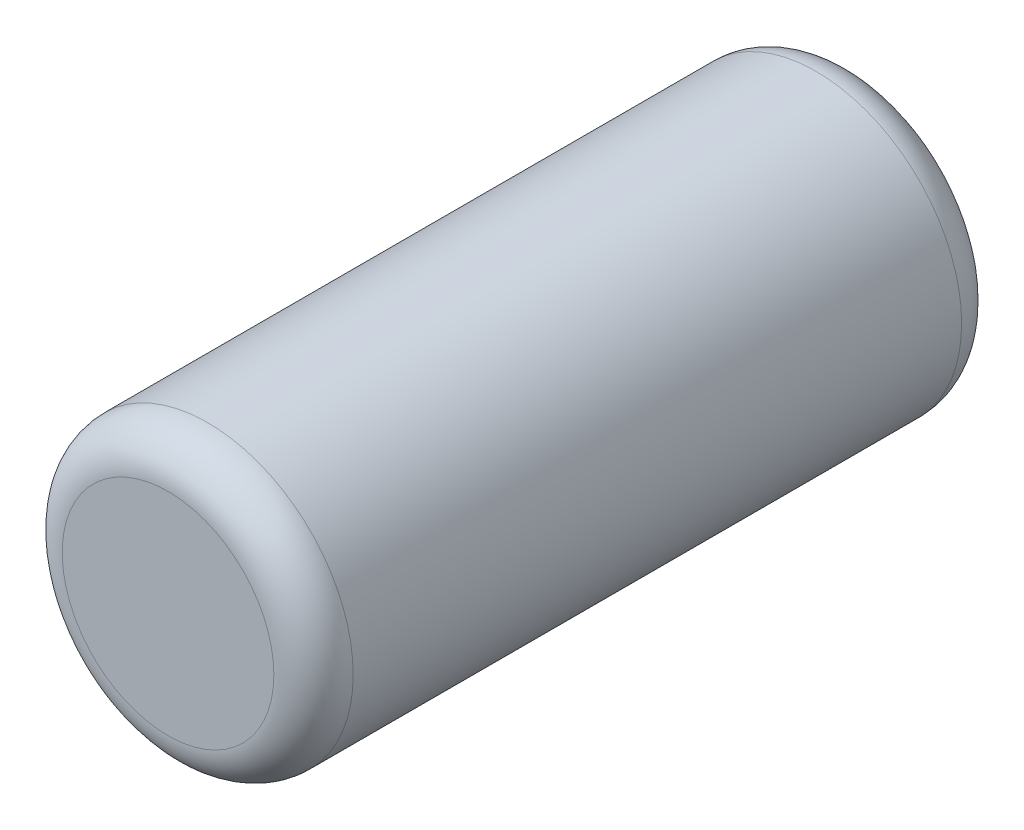
from build123d import *

# Parameters (mm, degrees)
SKETCH2_R           = 5.5
BOSS_EXTRUDE1_DEPTH = 13
FILLET1_R           = 1.5


with BuildPart() as part:
    # Sketch2 → Boss-Extrude1 (new body, symmetric)
    with BuildSketch(Plane.XY):
        Circle(SKETCH2_R)
    extrude(amount=BOSS_EXTRUDE1_DEPTH, both=True)

    # Fillet1
    fillet1_edges = [part.edges().sort_by_distance(p)[0] for p in [
        (-5.5, 0, -13),
        (-5.5, 0, 13),
    ]]
    fillet(fillet1_edges, radius=FILLET1_R)


solid = part.part
